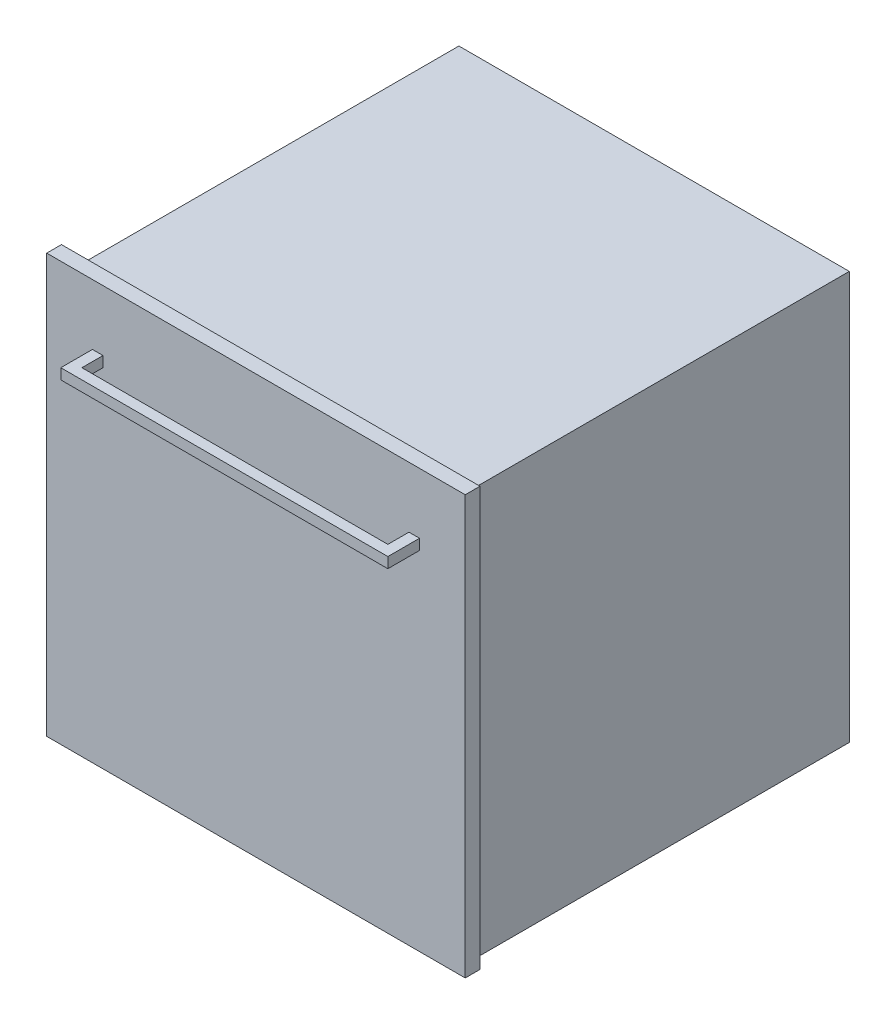
from build123d import *

# Parameters (mm, degrees)
SKETCH_1_W      = 555
SKETCH_1_H      = 545
EXTRUDE_1_DEPTH = 580
SKETCH_2_W      = 595
SKETCH_2_H      = 595
EXTRUDE_2_DEPTH = 21
SKETCH_3_W      = 15
SKETCH_3_H      = 15
EXTRUDE_3_DEPTH = 30
SKETCH_4_W      = 465
SKETCH_4_H      = 15
EXTRUDE_4_DEPTH = 15


with BuildPart() as part:
    # Эскиз1 → Бобышка-Вытянуть1 (new body)
    with BuildSketch(Plane(origin=(0, 0, 0), x_dir=(1, 0, 0), z_dir=(0, 1, 0))):
        Rectangle(SKETCH_1_W, SKETCH_1_H)
    extrude(amount=EXTRUDE_1_DEPTH)

    # Эскиз2 → Бобышка-Вытянуть2 (add)
    with BuildSketch(Plane.XY.offset(272.5)):
        with Locations((0, 300.5)):
            Rectangle(SKETCH_2_W, SKETCH_2_H)
    extrude(amount=EXTRUDE_2_DEPTH)

    # Эскиз3 → Бобышка-Вытянуть3 (add)
    with BuildSketch(Plane.XY.offset(293.5)):
        with Locations((-225, 504.413440556)):
            Rectangle(SKETCH_3_W, SKETCH_3_H)
        with Locations((225, 504.413440556)):
            Rectangle(SKETCH_3_W, SKETCH_3_H)
    extrude(amount=EXTRUDE_3_DEPTH)

    # Эскиз4 → Бобышка-Вытянуть4 (add)
    with BuildSketch(Plane.XY.offset(323.5)):
        with Locations((0, 504.413440556)):
            Rectangle(SKETCH_4_W, SKETCH_4_H)
    extrude(amount=EXTRUDE_4_DEPTH)


solid = part.part
